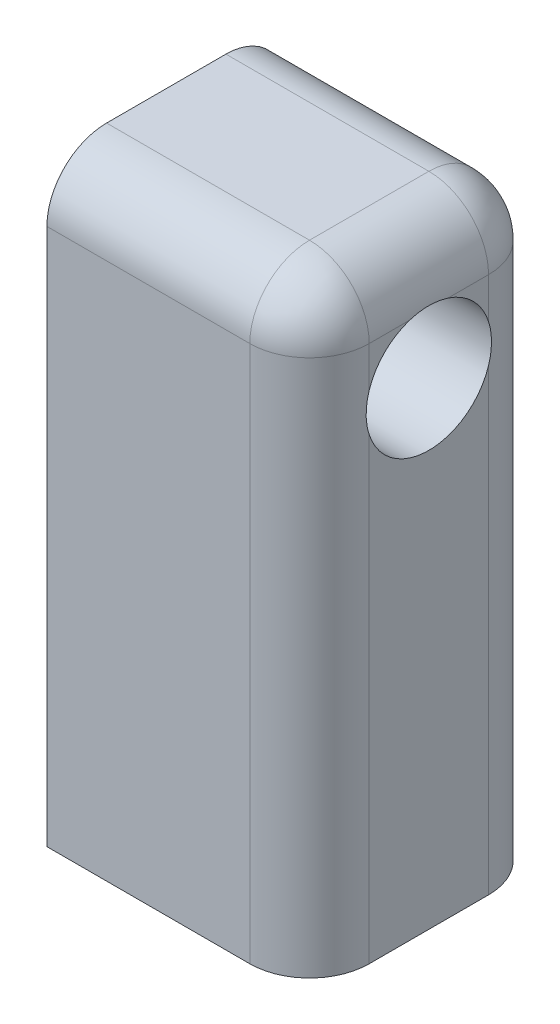
from build123d import *

# Parameters (mm, degrees)
SKETCH1_W           = 4.4
SKETCH1_H           = 4
BOSS_EXTRUDE1_DEPTH = 10
SKETCH2_R           = 0.925
CUT_EXTRUDE1_DEPTH  = 6
FILLET1_R           = 1
SKETCH3_R           = 1.05
CUT_EXTRUDE2_DEPTH  = 10


with BuildPart() as part:
    # Sketch1 → Boss-Extrude1 (new body)
    with BuildSketch(Plane(origin=(0, 0, 0), x_dir=(1, 0, 0), z_dir=(0, 1, 0))):
        with Locations((2.2, 2)):
            Rectangle(SKETCH1_W, SKETCH1_H)
    extrude(amount=BOSS_EXTRUDE1_DEPTH)

    # Sketch2 → Cut-Extrude1 (cut)
    with BuildSketch(Plane.XZ):
        with Locations((2.4, -2)):
            Circle(SKETCH2_R)
    extrude(amount=-CUT_EXTRUDE1_DEPTH, mode=Mode.SUBTRACT)

    # Fillet1
    fillet1_edges = [part.edges().sort_by_distance(p)[0] for p in [
        (4.4, 10, -2),
        (2.2, 10, -4),
        (4.4, 5, -4),
        (4.4, 5, 0),
        (2.2, 10, 0),
    ]]
    fillet(fillet1_edges, radius=FILLET1_R)

    # Sketch3 → Cut-Extrude2 (cut)
    with BuildSketch(Plane(origin=(4.4, 0, 0), x_dir=(0, 0, -1), z_dir=(1, 0, 0))):
        with Locations((2, 8)):
            Circle(SKETCH3_R)
    extrude(amount=-CUT_EXTRUDE2_DEPTH, mode=Mode.SUBTRACT)


solid = part.part
